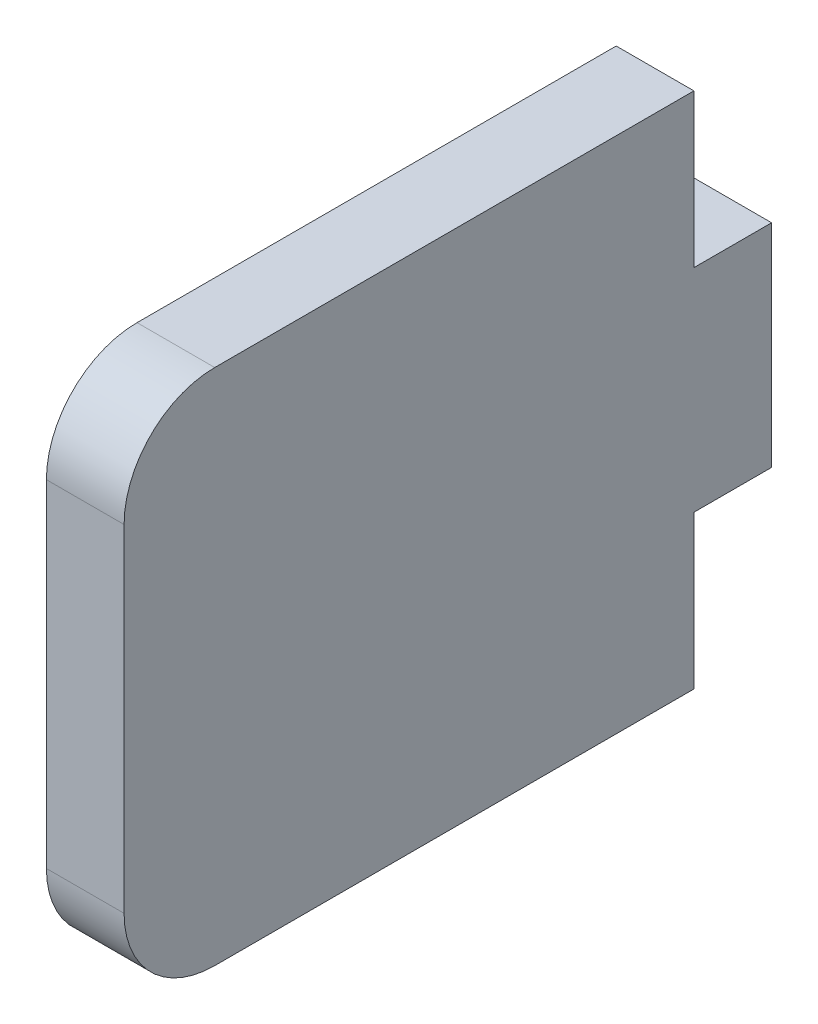
from build123d import *

# Parameters (mm, degrees)
BOSS_EXTRUDE1_DEPTH = 3
FILLET1_R           = 3.5


with BuildPart() as part:
    # Sketch1 → Boss-Extrude1 (new body)
    with BuildSketch(Plane(origin=(0, 0, 0), x_dir=(0, 0, -1), z_dir=(1, 0, 0))):
        Polygon((-11, 10), (11, 10), (11, 4.09), (14, 4.09), (14, -4.09), (11, -4.09), (11, -10), (-11, -10), align=None)
    extrude(amount=BOSS_EXTRUDE1_DEPTH)

    # Fillet1
    fillet1_edges = [part.edges().sort_by_distance(p)[0] for p in [
        (1.5, 10, 11),
        (1.5, -10, 11),
    ]]
    fillet(fillet1_edges, radius=FILLET1_R)


solid = part.part
